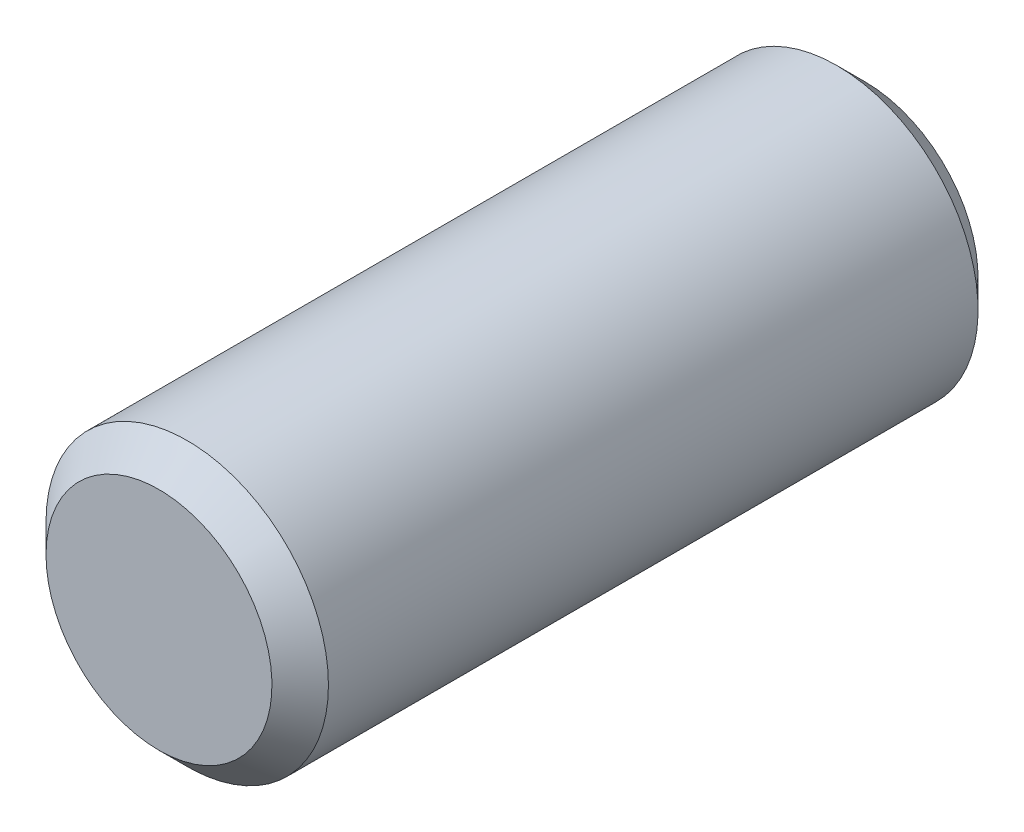
from build123d import *

# Parameters (mm, degrees)
ESQUISSE1_W     = 2.5
ESQUISSE1_H     = 0.5
CHANFREIN1_SIZE = 0.1


with BuildPart() as part:
    # Esquisse1 → Révolution1 (revolve)
    with BuildSketch(Plane(origin=(0, 0, 0), x_dir=(0, 0, -1), z_dir=(1, 0, 0))):
        Rectangle(ESQUISSE1_W, ESQUISSE1_H)
    revolve(axis=Axis((0, -0.25, -1.25), (0, 0, 1)))

    # Chanfrein1
    chanfrein1_edges = [part.edges().sort_by_distance(p)[0] for p in [
        (0, -0.75, -1.25),
        (0, -0.75, 1.25),
    ]]
    chamfer(chanfrein1_edges, length=CHANFREIN1_SIZE)


solid = part.part
